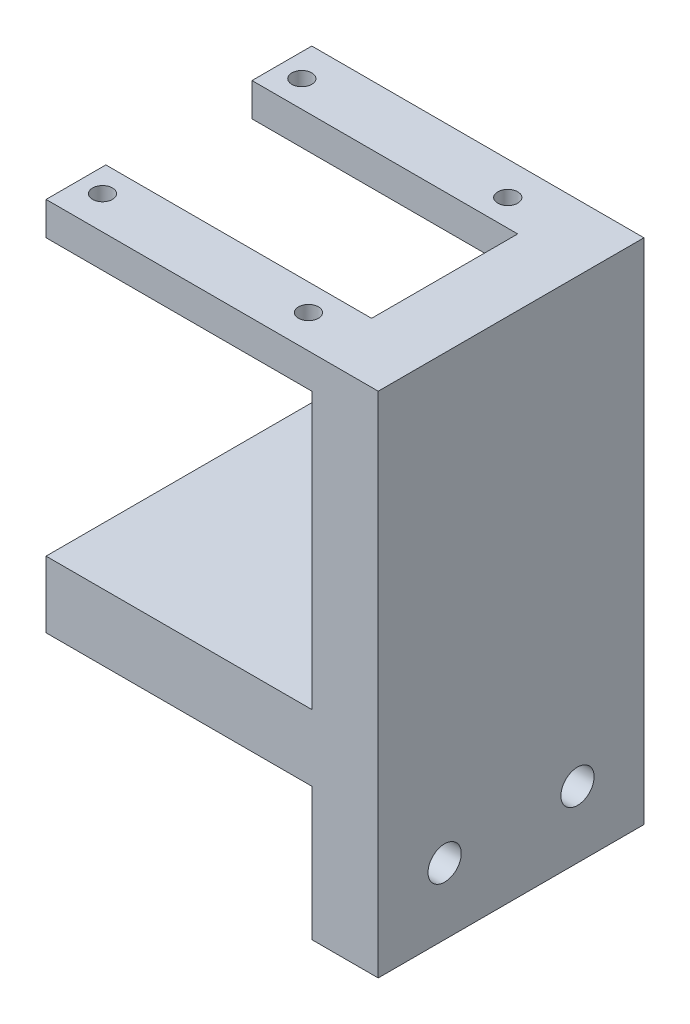
from build123d import *

# Parameters (mm, degrees)
SKETCH1_W           = 40
SKETCH1_H           = 56.5
SKETCH1_H_2         = 20
SKETCH1_R           = 2.5
BOSS_EXTRUDE1_DEPTH = 10
SKETCH3_W           = 40
SKETCH3_H           = 10
BOSS_EXTRUDE2_DEPTH = 40
SKETCH4_W           = 9
SKETCH4_H           = 5
BOSS_EXTRUDE3_DEPTH = 40
SKETCH5_R           = 1.5
CUT_EXTRUDE1_DEPTH  = 5


with BuildPart() as part:
    # Sketch1 → Boss-Extrude1 (new body)
    with BuildSketch(Plane(origin=(0, 0, 0), x_dir=(0, 0, -1), z_dir=(1, 0, 0))):
        with Locations((0, 28.25)):
            Rectangle(SKETCH1_W, SKETCH1_H)
        with Locations((0, -10)):
            Rectangle(SKETCH1_W, SKETCH1_H_2)
        with Locations((10, -10)):
            Circle(SKETCH1_R, mode=Mode.SUBTRACT)
        with Locations((-10, -10)):
            Circle(SKETCH1_R, mode=Mode.SUBTRACT)
    extrude(amount=BOSS_EXTRUDE1_DEPTH)

    # Sketch3 → Boss-Extrude2 (add)
    with BuildSketch(Plane.ZY):
        with Locations((0, 5)):
            Rectangle(SKETCH3_W, SKETCH3_H)
    extrude(amount=BOSS_EXTRUDE2_DEPTH)

    # Sketch4 → Boss-Extrude3 (add)
    with BuildSketch(Plane.ZY):
        with Locations((-15.5, 54)):
            Rectangle(SKETCH4_W, SKETCH4_H)
    boss_extrude3 = extrude(amount=BOSS_EXTRUDE3_DEPTH)

    # Sketch5 → Cut-Extrude1 (cut)
    with BuildSketch(Plane(origin=(0, 56.5, 0), x_dir=(1, 0, 0), z_dir=(0, 1, 0))):
        with Locations((-36.5, 15)):
            Circle(SKETCH5_R)
        with Locations((-5.5, 15)):
            Circle(SKETCH5_R)
    cut_extrude1 = extrude(amount=-CUT_EXTRUDE1_DEPTH, mode=Mode.SUBTRACT)

    # Mirror2: Boss-Extrude3, Cut-Extrude1 across plane
    add(boss_extrude3.mirror(Plane.XY))
    add(cut_extrude1.mirror(Plane.XY), mode=Mode.SUBTRACT)


solid = part.part
